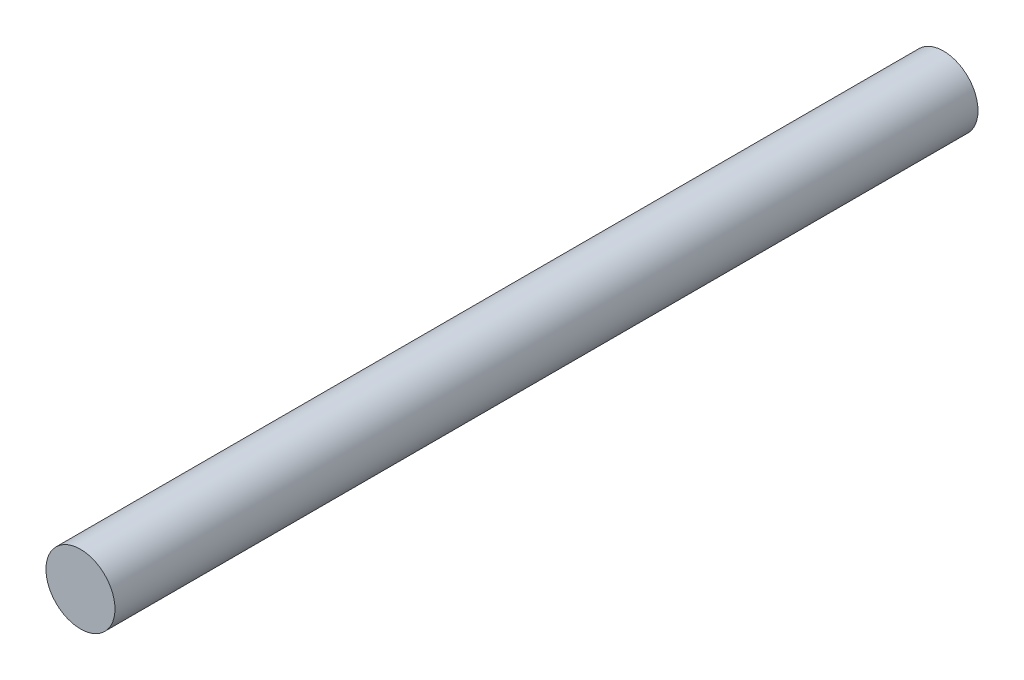
from build123d import *

# Parameters (mm, degrees)
BOSS_EXTRUDE1_DEPTH      = 25
BOSS_EXTRUDE1_DEPTH_BACK = 25
SKETCH1_R                = 2


with BuildPart() as part:
    # Sketch1 → Boss-Extrude1 (new, two sides: drawn at the far end of the back side and taken through both)
    with BuildSketch(Plane.XY.offset(-BOSS_EXTRUDE1_DEPTH_BACK)):
        Circle(SKETCH1_R)
    extrude(amount=BOSS_EXTRUDE1_DEPTH + BOSS_EXTRUDE1_DEPTH_BACK)


solid = part.part
